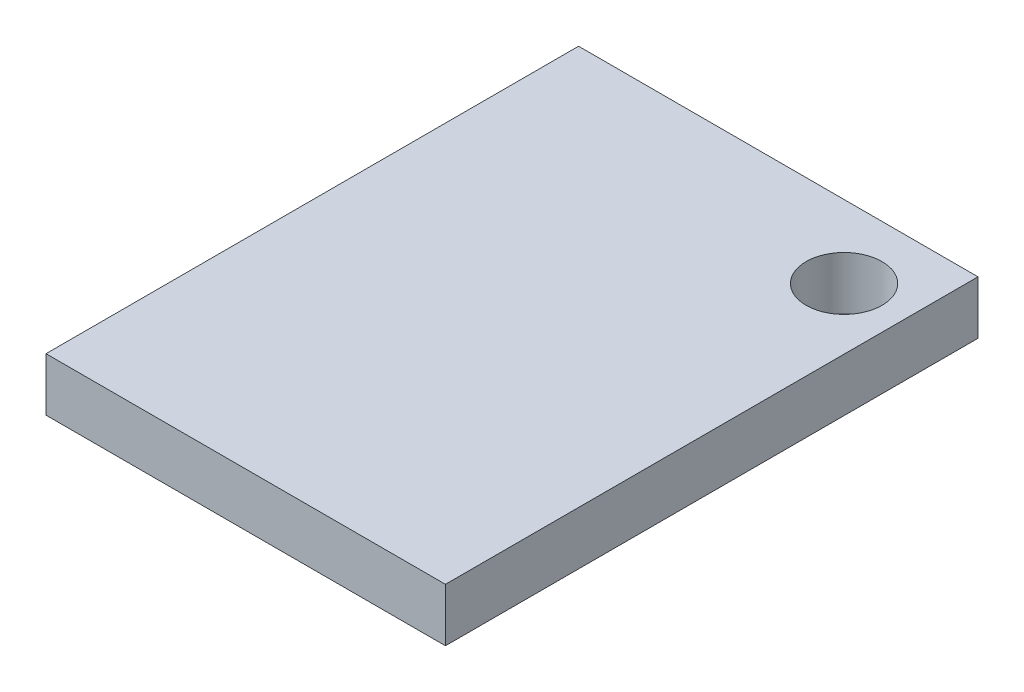
from build123d import *

# Parameters (mm, degrees)
SKETCH1_W           = 15
SKETCH1_H           = 20
BOSS_EXTRUDE1_DEPTH = 2
SKETCH2_R           = 1.425198778
CUT_EXTRUDE1_DEPTH  = 3


with BuildPart() as part:
    # Sketch1 → Boss-Extrude1 (new body)
    with BuildSketch(Plane(origin=(0, 0, 0), x_dir=(1, 0, 0), z_dir=(0, 1, 0))):
        Rectangle(SKETCH1_W, SKETCH1_H)
    extrude(amount=BOSS_EXTRUDE1_DEPTH)

    # Sketch2 → Cut-Extrude1 (cut, through all)
    with BuildSketch(Plane(origin=(0, 2, 0), x_dir=(1, 0, 0), z_dir=(0, 1, 0))):
        with Locations((5.20095182, 7.269623024)):
            Circle(SKETCH2_R)
    extrude(amount=-CUT_EXTRUDE1_DEPTH, mode=Mode.SUBTRACT)


solid = part.part
